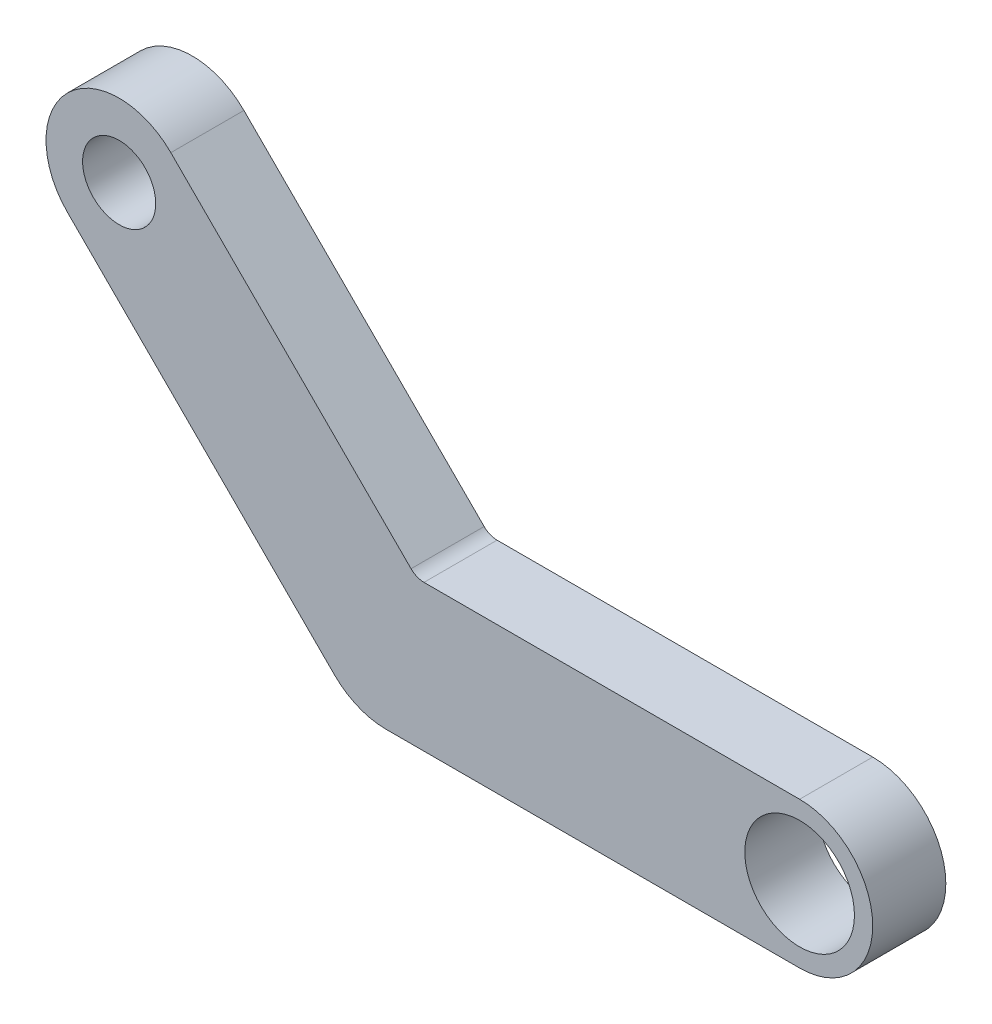
from build123d import *

# Parameters (mm, degrees)
SKETCH1_R           = 0.75
SKETCH1_R_2         = 0.5
BOSS_EXTRUDE1_DEPTH = 1


with BuildPart() as part:
    # Sketch1 → Boss-Extrude1 (new body)
    with BuildSketch(Plane.XY):
        with BuildLine():
            Line((0.517766953, 1), (5.65685425, 1))
            ThreePointArc((5.65685425, 1), (6.65685425, 0), (5.65685425, -1))
            Line((5.65685425, -1), (0, -1))
            ThreePointArc((0, -1), (-0.382683432, -0.923879533), (-0.707106781, -0.707106781))
            Line((-0.707106781, -0.707106781), (-4.359420354, 2.945206792))
            ThreePointArc((-4.359420354, 2.945206792), (-4.359420354, 4.359420354), (-2.945206792, 4.359420354))
            Line((-2.945206792, 4.359420354), (0.340990258, 1.073223305))
            ThreePointArc((0.340990258, 1.073223305), (0.422096095, 1.019030117), (0.517766953, 1))
        make_face()
        with Locations((5.65685425, 0)):
            Circle(SKETCH1_R, mode=Mode.SUBTRACT)
        with Locations((-3.652313573, 3.652313573)):
            Circle(SKETCH1_R_2, mode=Mode.SUBTRACT)
    extrude(amount=BOSS_EXTRUDE1_DEPTH)


solid = part.part
